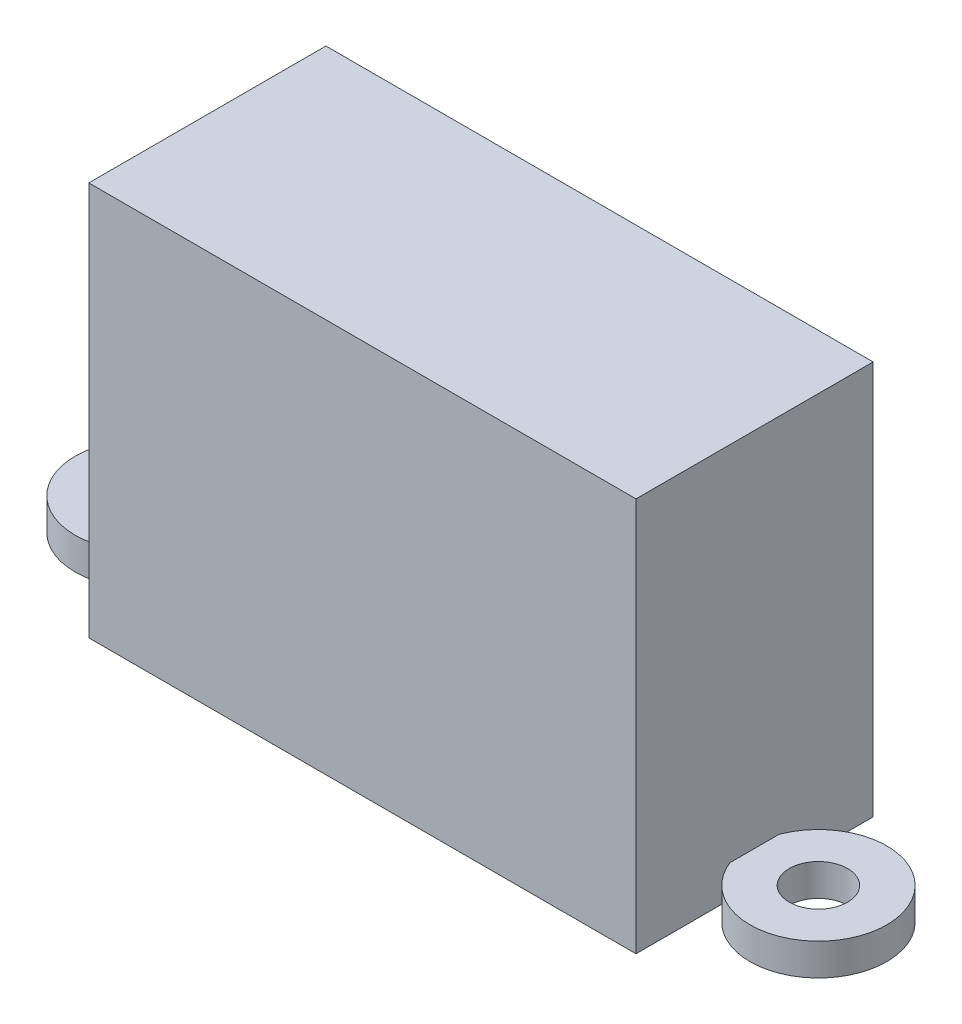
from build123d import *

# Parameters (mm, degrees)
SKETCH1_R             = 3.75
SKETCH1_R_2           = 1.6
BOSS_EXTRUDE1_DEPTH   = 1.75
BOSS_EXTRUDE1_2_DEPTH = 1.75
SKETCH2_W             = 30
SKETCH2_H             = 13
BOSS_EXTRUDE2_DEPTH   = 21.6


with BuildPart() as part:
    # Sketch1 → Boss-Extrude1 (new body)
    with BuildSketch(Plane(origin=(0, 0, 0), x_dir=(1, 0, 0), z_dir=(0, 1, 0))):
        with Locations((-18.5, 0)):
            Circle(SKETCH1_R)
        with Locations((-18.5, 0)):
            Circle(SKETCH1_R_2, mode=Mode.SUBTRACT)
    extrude(amount=BOSS_EXTRUDE1_DEPTH)


with BuildPart() as body_2:
    # Sketch1 → Boss-Extrude1 2 (new body)
    with BuildSketch(Plane(origin=(0, 0, 0), x_dir=(1, 0, 0), z_dir=(0, 1, 0))):
        with Locations((18.5, 0)):
            Circle(SKETCH1_R)
        with Locations((18.5, 0)):
            Circle(SKETCH1_R_2, mode=Mode.SUBTRACT)
    extrude(amount=BOSS_EXTRUDE1_2_DEPTH)


with BuildPart() as body_3:
    # Sketch2 → Boss-Extrude2 (new body)
    with BuildSketch(Plane(origin=(0, 0, 0), x_dir=(1, 0, 0), z_dir=(0, 1, 0))):
        Rectangle(SKETCH2_W, SKETCH2_H)
    extrude(amount=BOSS_EXTRUDE2_DEPTH)


solid = Compound([part.part, body_2.part, body_3.part])
